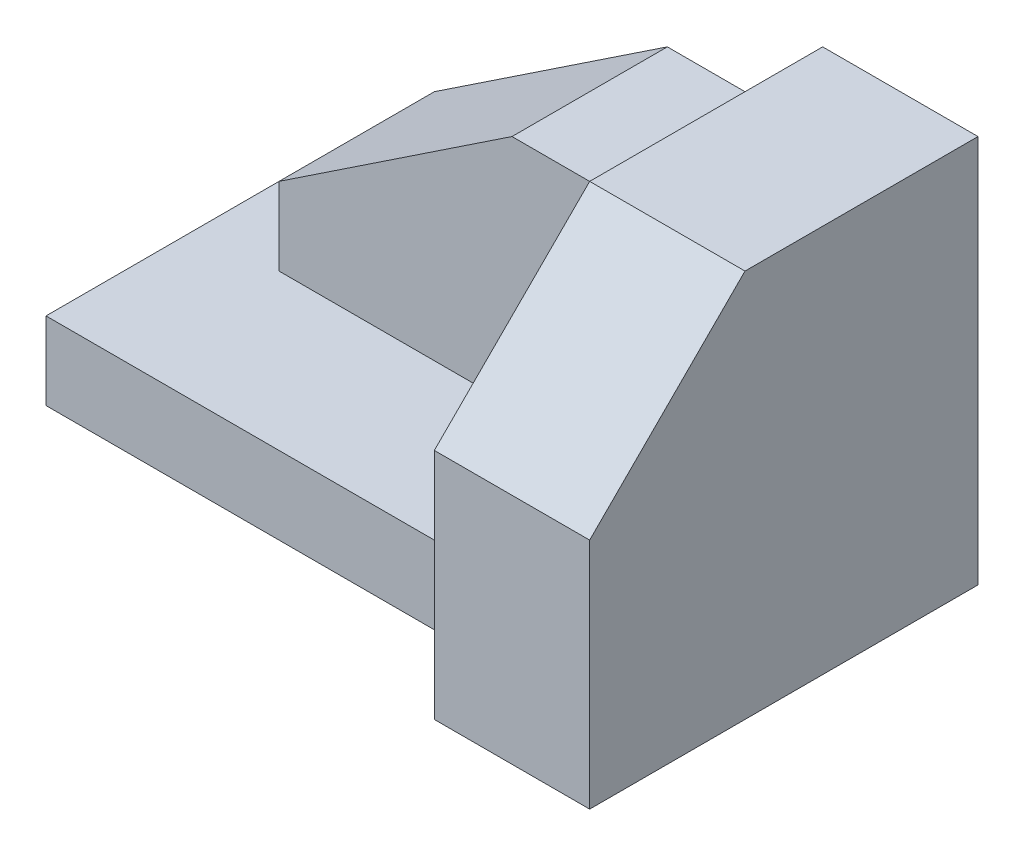
from build123d import *

# Parameters (mm, degrees)
BOSS_EXTRUDE1_DEPTH = 10
SKETCH3_W           = 20
SKETCH3_H           = 50
BOSS_EXTRUDE2_DEPTH = 40
CUT_EXTRUDE1_DEPTH  = 40
SKETCH5_W           = 50
SKETCH5_H           = 20
BOSS_EXTRUDE3_DEPTH = 30
CUT_EXTRUDE2_DEPTH  = 30


with BuildPart() as part:
    # Sketch2 → Boss-Extrude1 (new body)
    with BuildSketch(Plane(origin=(0, 0, 0), x_dir=(1, 0, 0), z_dir=(0, 1, 0))):
        Polygon((0, 50), (0, 10), (60, 10), (60, 0), (80, 0), (80, 50), align=None)
    extrude(amount=BOSS_EXTRUDE1_DEPTH)

    # Sketch3 → Boss-Extrude2 (add)
    with BuildSketch(Plane(origin=(0, 10, 0), x_dir=(1, 0, 0), z_dir=(0, 1, 0))):
        with Locations((70, 25)):
            Rectangle(SKETCH3_W, SKETCH3_H)
    extrude(amount=BOSS_EXTRUDE2_DEPTH)

    # Sketch4 → Cut-Extrude1 (cut)
    with BuildSketch(Plane(origin=(80, 0, 0), x_dir=(0, 0, -1), z_dir=(1, 0, 0))):
        Polygon((20, 50), (0, 30), (0, 50), align=None)
    extrude(amount=-CUT_EXTRUDE1_DEPTH, mode=Mode.SUBTRACT)

    # Sketch5 → Boss-Extrude3 (add)
    with BuildSketch(Plane(origin=(0, 10, 0), x_dir=(1, 0, 0), z_dir=(0, 1, 0))):
        with Locations((35, 40)):
            Rectangle(SKETCH5_W, SKETCH5_H)
    extrude(amount=BOSS_EXTRUDE3_DEPTH)

    # Sketch6 → Cut-Extrude2 (cut)
    with BuildSketch(Plane.XY.offset(-30)):
        Polygon((40, 40), (10, 20), (10, 40), align=None)
    extrude(amount=-CUT_EXTRUDE2_DEPTH, mode=Mode.SUBTRACT)


solid = part.part
